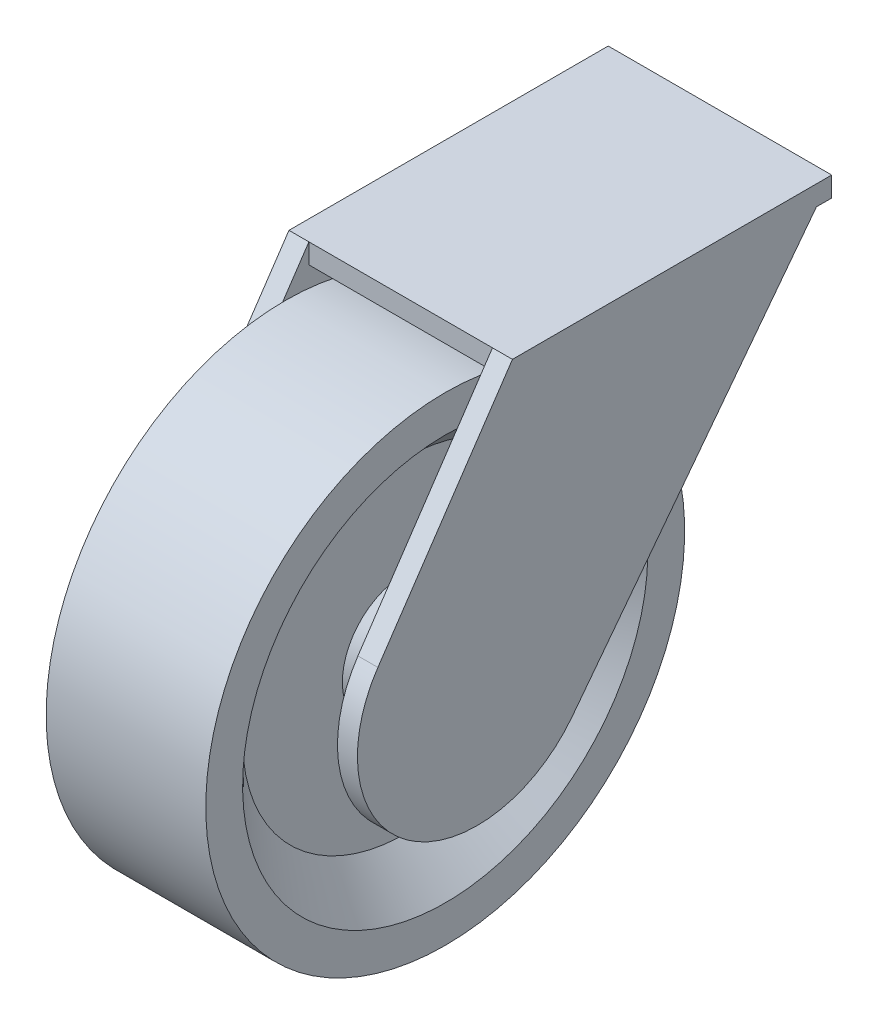
from build123d import *

# Parameters (mm, degrees)
SKETCH3_R           = 7.5
BOSS_EXTRUDE1_DEPTH = 8
BOSS_EXTRUDE2_DEPTH = 5
SKETCH5_W           = 56
SKETCH5_H           = 80
BOSS_EXTRUDE3_DEPTH = 5
SCALE1_SCALE        = 0.5


with BuildPart() as part:
    # Sketch1 → Revolve1 (revolve)
    with BuildSketch(Plane.XY):
        Polygon((-40, 60), (0, 60), (0, 50.773502692), (-10, 40.773502692), (-10, 15.773502692), (0, 10), (0, 0), (-40, 0), (-40, 10), (-30, 15.773502692), (-30, 40.773502692), (-40, 50.773502692), align=None)
    revolve(axis=Axis((0, 0, 0), (-1, 0, 0)))

    # Sketch3 → Boss-Extrude1 (add)
    with BuildSketch(Plane(origin=(0, 0, 0), x_dir=(0, 0, -1), z_dir=(1, 0, 0))):
        Circle(SKETCH3_R)
    boss_extrude1 = extrude(amount=BOSS_EXTRUDE1_DEPTH)

    # Sketch4 → Boss-Extrude2 (add)
    with BuildSketch(Plane(origin=(8, 0, 0), x_dir=(0, 0, -1), z_dir=(1, 0, 0))):
        with BuildLine():
            Line((8.84577787, 66.773419664), (88.84577787, 66.773419664))
            Line((88.84577787, 66.773419664), (23.828381591, -18.226580336))
            ThreePointArc((23.828381591, -18.226580336), (-17.50778863, -24.361390299), (-24.872723871, 16.773419664))
            Line((-24.872723871, 16.773419664), (8.84577787, 66.773419664))
        make_face()
    boss_extrude2 = extrude(amount=-BOSS_EXTRUDE2_DEPTH)

    # Mirror1: Boss-Extrude1, Boss-Extrude2 across plane
    add(boss_extrude1.mirror(Plane(origin=(-20, 0, 0), x_dir=(0, 0, 1), z_dir=(1, 0, 0))))
    add(boss_extrude2.mirror(Plane(origin=(-20, 0, 0), x_dir=(0, 0, 1), z_dir=(1, 0, 0))))

    # Sketch5 → Boss-Extrude3 (add)
    with BuildSketch(Plane(origin=(0, 66.773419664, 0), x_dir=(1, 0, 0), z_dir=(0, 1, 0))):
        with Locations((-20, 48.84577787)):
            Rectangle(SKETCH5_W, SKETCH5_H)
    extrude(amount=-BOSS_EXTRUDE3_DEPTH)


with BuildPart() as part_1:
    # Scale1: scaled about (-20, 6.593417993, -5.351287219)
    add(part.part.scale(SCALE1_SCALE).moved(Location((-10, 3.296708997, -2.675643609))))


solid = part_1.part
